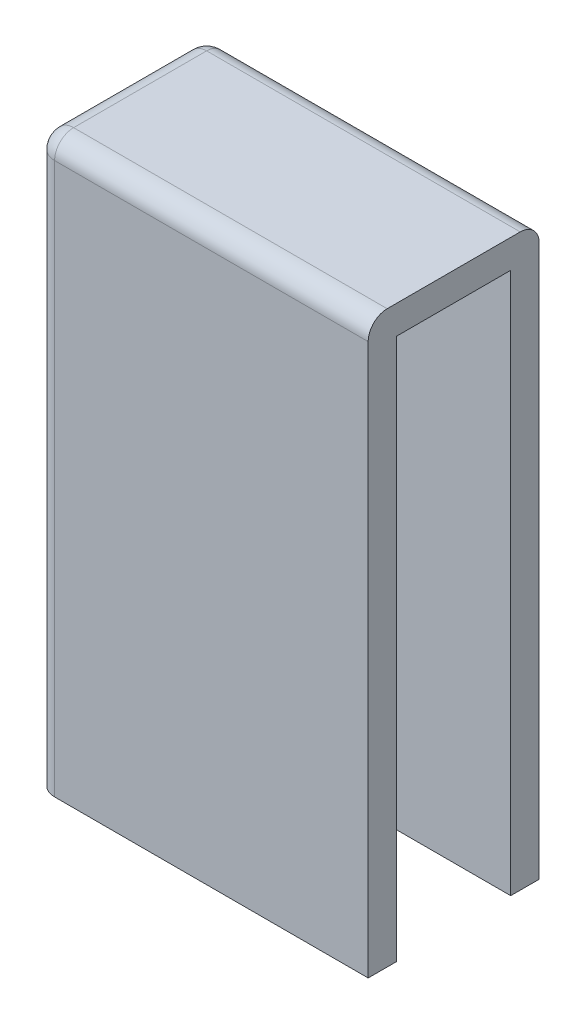
from build123d import *

# Parameters (mm, degrees)
BOSS_EXTRUDE1_DEPTH = 57
SKETCH2_W           = 35
SKETCH2_H           = 18
BOSS_EXTRUDE2_DEPTH = 3
FILLET1_R           = 2


with BuildPart() as part:
    # Sketch1 → Boss-Extrude1 (new body)
    with BuildSketch(Plane(origin=(0, 0, 0), x_dir=(1, 0, 0), z_dir=(0, 1, 0))):
        Polygon((0, 0), (-32, 0), (-32, 12), (0, 12), (0, 15), (-35, 15), (-35, -3), (0, -3), align=None)
    extrude(amount=BOSS_EXTRUDE1_DEPTH)

    # Sketch2 → Boss-Extrude2 (add)
    with BuildSketch(Plane(origin=(0, 57, 0), x_dir=(1, 0, 0), z_dir=(0, 1, 0))):
        with Locations((-17.5, 6)):
            Rectangle(SKETCH2_W, SKETCH2_H)
    extrude(amount=BOSS_EXTRUDE2_DEPTH)

    # Fillet1
    fillet1_edges = [part.edges().sort_by_distance(p)[0] for p in [
        (-35, 30, 3),
        (-35, 30, -15),
        (-35, 60, -6),
        (-17.5, 60, 3),
        (-17.5, 60, -15),
    ]]
    fillet(fillet1_edges, radius=FILLET1_R)


solid = part.part
